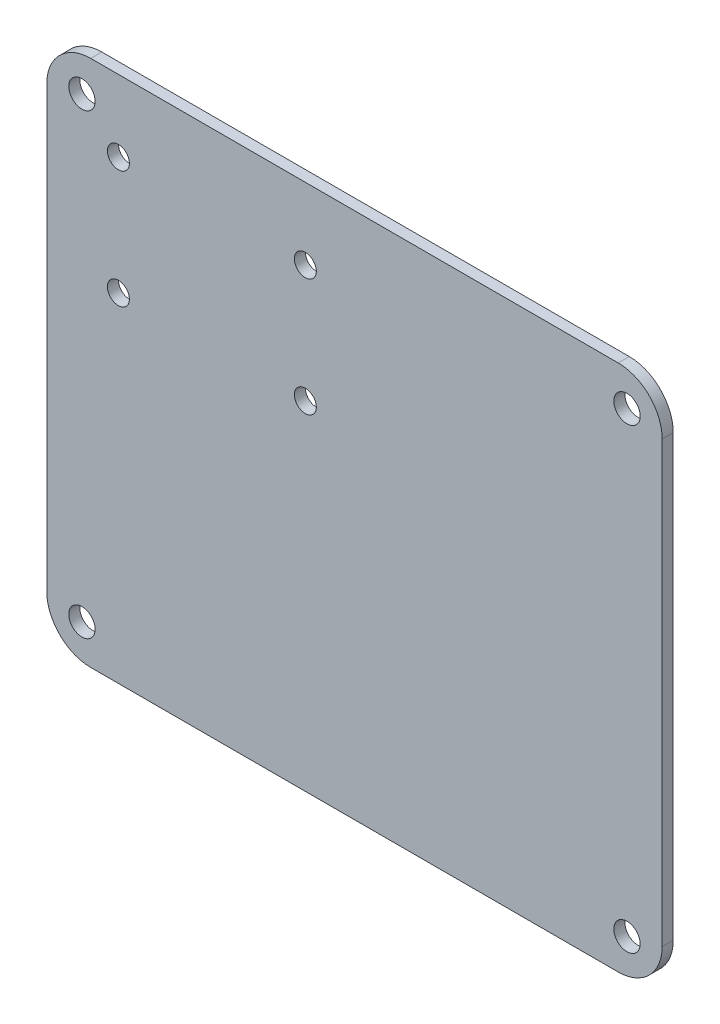
from build123d import *

# Parameters (mm, degrees)
SKETCH1_W           = 88.9
SKETCH1_H           = 76.2
BOSS_EXTRUDE1_DEPTH = 1.6
SKETCH2_R           = 1.5875
CUT_EXTRUDE1_DEPTH  = 2.6
SKETCH4_R           = 1.905
CUT_EXTRUDE2_DEPTH  = 2.6
FILLET1_R           = 6.35


with BuildPart() as part:
    # Sketch1 → Boss-Extrude1 (new body)
    with BuildSketch(Plane.XY):
        with Locations((28.959521177, 30.063142475)):
            Rectangle(SKETCH1_W, SKETCH1_H)
    extrude(amount=BOSS_EXTRUDE1_DEPTH)

    # Sketch2 → Cut-Extrude1 (cut, through all)
    with BuildSketch(Plane(origin=(0, 0, 0), x_dir=(-1, 0, 0), z_dir=(0, 0, -1))):
        with Locations((5.140478823, 57.813142475)):
            Circle(SKETCH2_R)
        with Locations((-21.859521177, 57.813142475)):
            Circle(SKETCH2_R)
        with Locations((-21.859521177, 40.813142475)):
            Circle(SKETCH2_R)
        with Locations((5.140478823, 40.813142475)):
            Circle(SKETCH2_R)
    extrude(amount=-CUT_EXTRUDE1_DEPTH, mode=Mode.SUBTRACT)

    # Sketch4 → Cut-Extrude2 (cut, through all)
    with BuildSketch(Plane(origin=(0, 0, 0), x_dir=(-1, 0, 0), z_dir=(0, 0, -1))):
        with Locations((10.410478823, 63.083142475)):
            Circle(SKETCH4_R)
        with Locations((-68.329521177, 63.083142475)):
            Circle(SKETCH4_R)
        with Locations((-68.329521177, -2.956857525)):
            Circle(SKETCH4_R)
        with Locations((10.410478823, -2.956857525)):
            Circle(SKETCH4_R)
    extrude(amount=-CUT_EXTRUDE2_DEPTH, mode=Mode.SUBTRACT)

    # Fillet1
    fillet1_edges = [part.edges().sort_by_distance(p)[0] for p in [
        (-15.490478823, 68.163142475, 0.8),
        (73.409521177, 68.163142475, 0.8),
        (73.409521177, -8.036857525, 0.8),
        (-15.490478823, -8.036857525, 0.8),
    ]]
    fillet(fillet1_edges, radius=FILLET1_R)


solid = part.part
